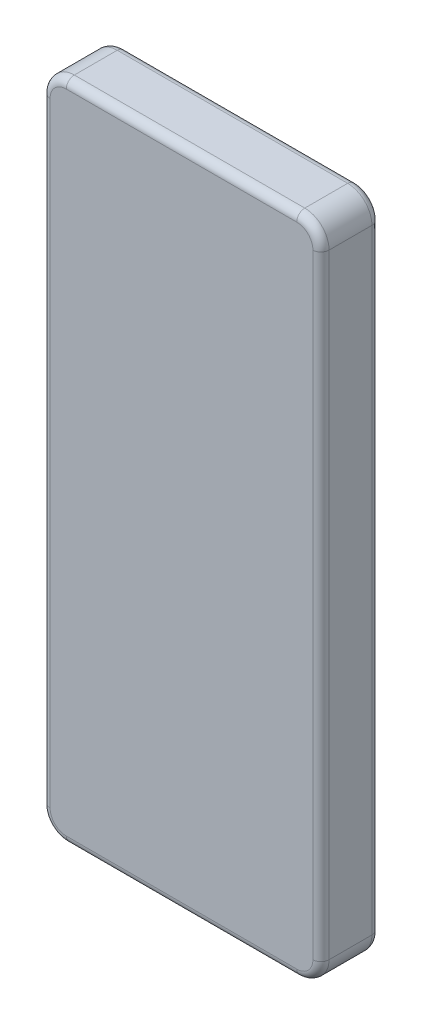
from build123d import *

# Parameters (mm, degrees)
EXTRUDE_1_DEPTH = 7.3
FILLET_1_R      = 1


with BuildPart() as part:
    # 草图1 → 凸台-拉伸1 (new body)
    with BuildSketch(Plane.XY):
        with BuildLine():
            Line((-14.25, 41), (14.25, 41))
            ThreePointArc((14.25, 41), (16.371320344, 40.121320344), (17.25, 38))
            Line((17.25, 38), (17.25, -38))
            ThreePointArc((17.25, -38), (16.371320344, -40.121320344), (14.25, -41))
            Line((14.25, -41), (-14.25, -41))
            ThreePointArc((-14.25, -41), (-16.371320344, -40.121320344), (-17.25, -38))
            Line((-17.25, -38), (-17.25, 38))
            ThreePointArc((-17.25, 38), (-16.371320344, 40.121320344), (-14.25, 41))
        make_face()
    extrude(amount=EXTRUDE_1_DEPTH)

    # 圆角1
    fillet_1_edges = [part.edges().sort_by_distance(p)[0] for p in [
        (17.25, 0, 0),
        (16.371320344, -40.121320344, 0),
        (0, -41, 0),
        (-16.371320344, -40.121320344, 0),
        (16.371320344, -40.121320344, 7.3),
        (17.25, 0, 7.3),
        (16.371320344, 40.121320344, 7.3),
        (0, 41, 7.3),
        (-16.371320344, 40.121320344, 7.3),
        (-17.25, 0, 7.3),
        (-16.371320344, -40.121320344, 7.3),
        (-17.25, 0, 0),
        (0, -41, 7.3),
        (-16.371320344, 40.121320344, 0),
        (0, 41, 0),
        (16.371320344, 40.121320344, 0),
    ]]
    fillet(fillet_1_edges, radius=FILLET_1_R)


solid = part.part
